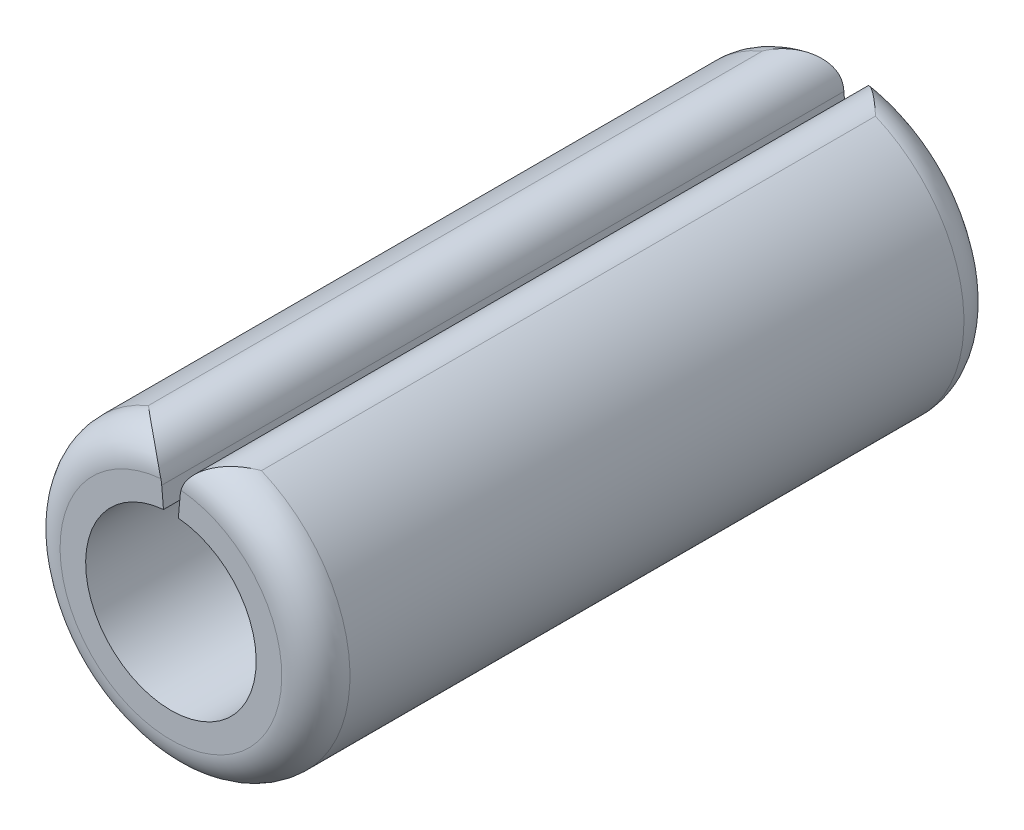
from build123d import *

# Parameters (mm, degrees)
BOSS_EXTRUDE1_DEPTH      = 2
BOSS_EXTRUDE1_DEPTH_BACK = 2
FILLET2_R                = 0.2


with BuildPart() as part:
    # Sketch1 → Boss-Extrude1 (new, two sides: drawn at the far end of the back side and taken through both)
    with BuildSketch(Plane.XY.offset(-BOSS_EXTRUDE1_DEPTH_BACK)):
        with BuildLine():
            Line((0.074082381, 0.846765493), (0.043577871, 0.498097349))
            ThreePointArc((0.043577871, 0.498097349), (0, -0.5), (-0.043577871, 0.498097349))
            Line((-0.043577871, 0.498097349), (-0.074082381, 0.846765493))
            ThreePointArc((-0.074082381, 0.846765493), (0, -0.85), (0.074082381, 0.846765493))
        make_face()
    extrude(amount=BOSS_EXTRUDE1_DEPTH + BOSS_EXTRUDE1_DEPTH_BACK)

    # Fillet2
    fillet2_edges = [part.edges().sort_by_distance(p)[0] for p in [
        (0, -0.85, 2),
        (0, -0.85, -2),
        (0.074082381, 0.846765493, 0),
        (-0.074082381, 0.846765493, 0),
    ]]
    fillet(fillet2_edges, radius=FILLET2_R)


solid = part.part
